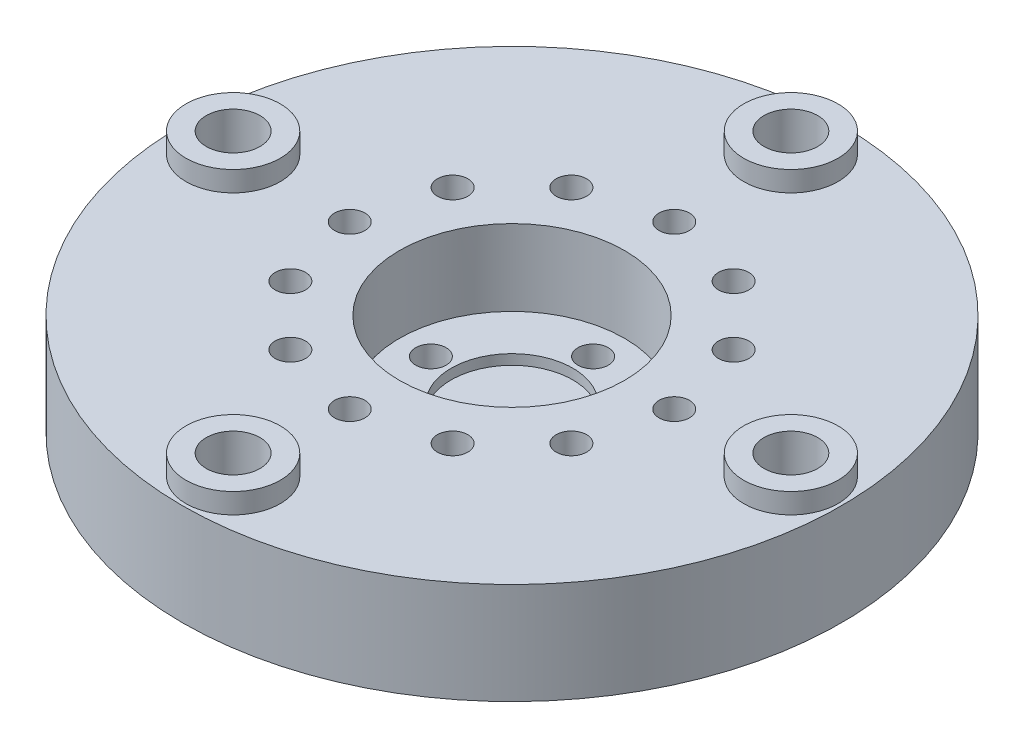
from build123d import *

# Parameters (mm, degrees)
SKETCH1_R           = 32.5
SKETCH1_R_2         = 2.65
SKETCH1_R_3         = 11.1
BOSS_EXTRUDE1_DEPTH = 3
SKETCH2_R           = 4.65
SKETCH2_R_2         = 2.65
BOSS_EXTRUDE2_DEPTH = 2
SKETCH3_R           = 32.5
SKETCH3_R_2         = 11.1
SKETCH3_R_3         = 4.25
BOSS_EXTRUDE3_DEPTH = 7
SKETCH4_R           = 11.1
SKETCH4_R_2         = 1.5
BOSS_EXTRUDE4_DEPTH = 2.5
SKETCH5_R           = 1.5
CUT_EXTRUDE1_DEPTH  = 13
SKETCH6_R           = 6
CUT_EXTRUDE2_DEPTH  = 1


with BuildPart() as part:
    # Sketch1 → Boss-Extrude1 (new body)
    with BuildSketch(Plane(origin=(0, 0, 0), x_dir=(1, 0, 0), z_dir=(0, 1, 0))):
        Circle(SKETCH1_R)
        with Locations((0, 27.5)):
            Circle(SKETCH1_R_2, mode=Mode.SUBTRACT)
        with Locations((27.5, 0)):
            Circle(SKETCH1_R_2, mode=Mode.SUBTRACT)
        with Locations((0, -27.5)):
            Circle(SKETCH1_R_2, mode=Mode.SUBTRACT)
        with Locations((-27.5, 0)):
            Circle(SKETCH1_R_2, mode=Mode.SUBTRACT)
        Circle(SKETCH1_R_3, mode=Mode.SUBTRACT)
    extrude(amount=BOSS_EXTRUDE1_DEPTH)

    # Sketch2 → Boss-Extrude2 (add)
    with BuildSketch(Plane(origin=(0, 3, 0), x_dir=(1, 0, 0), z_dir=(0, 1, 0))):
        with Locations((0, -27.5)):
            Circle(SKETCH2_R)
        with Locations((0, -27.5)):
            Circle(SKETCH2_R_2, mode=Mode.SUBTRACT)
        with Locations((27.5, 0)):
            Circle(SKETCH2_R)
        with Locations((27.5, 0)):
            Circle(SKETCH2_R_2, mode=Mode.SUBTRACT)
        with Locations((0, 27.5)):
            Circle(SKETCH2_R)
        with Locations((0, 27.5)):
            Circle(SKETCH2_R_2, mode=Mode.SUBTRACT)
        with Locations((-27.5, 0)):
            Circle(SKETCH2_R)
        with Locations((-27.5, 0)):
            Circle(SKETCH2_R_2, mode=Mode.SUBTRACT)
    extrude(amount=BOSS_EXTRUDE2_DEPTH)

    # Sketch3 → Boss-Extrude3 (add)
    with BuildSketch(Plane(origin=(0, 0, 0), x_dir=(-1, 0, 0), z_dir=(0, -1, 0))):
        Circle(SKETCH3_R)
        Circle(SKETCH3_R_2, mode=Mode.SUBTRACT)
        with Locations((0, 27.5)):
            Circle(SKETCH3_R_3, mode=Mode.SUBTRACT)
        with Locations((27.5, 0)):
            Circle(SKETCH3_R_3, mode=Mode.SUBTRACT)
        with Locations((0, -27.5)):
            Circle(SKETCH3_R_3, mode=Mode.SUBTRACT)
        with Locations((-27.5, 0)):
            Circle(SKETCH3_R_3, mode=Mode.SUBTRACT)
    extrude(amount=BOSS_EXTRUDE3_DEPTH)

    # Sketch4 → Boss-Extrude4 (add)
    with BuildSketch(Plane(origin=(0, -7, 0), x_dir=(-1, 0, 0), z_dir=(0, -1, 0))):
        Circle(SKETCH4_R)
        with Locations((0, 8)):
            Circle(SKETCH4_R_2, mode=Mode.SUBTRACT)
        with Locations((8, 0)):
            Circle(SKETCH4_R_2, mode=Mode.SUBTRACT)
        with Locations((0, -8)):
            Circle(SKETCH4_R_2, mode=Mode.SUBTRACT)
        with Locations((-8, 0)):
            Circle(SKETCH4_R_2, mode=Mode.SUBTRACT)
    extrude(amount=-BOSS_EXTRUDE4_DEPTH)

    # Sketch5 → Cut-Extrude1 (cut, through all)
    with BuildSketch(Plane.XZ.offset(7)):
        with Locations((0, 16)):
            Circle(SKETCH5_R)
        with Locations((8, 13.856406461)):
            Circle(SKETCH5_R)
        with Locations((13.856406461, 8)):
            Circle(SKETCH5_R)
        with Locations((16, 0)):
            Circle(SKETCH5_R)
        with Locations((13.856406461, -8)):
            Circle(SKETCH5_R)
        with Locations((8, -13.856406461)):
            Circle(SKETCH5_R)
        with Locations((0, -16)):
            Circle(SKETCH5_R)
        with Locations((-8, -13.856406461)):
            Circle(SKETCH5_R)
        with Locations((-13.856406461, -8)):
            Circle(SKETCH5_R)
        with Locations((-16, 0)):
            Circle(SKETCH5_R)
        with Locations((-13.856406461, 8)):
            Circle(SKETCH5_R)
        with Locations((-8, 13.856406461)):
            Circle(SKETCH5_R)
    extrude(amount=-CUT_EXTRUDE1_DEPTH, mode=Mode.SUBTRACT)

    # Sketch6 → Cut-Extrude2 (cut)
    with BuildSketch(Plane(origin=(0, -4.5, 0), x_dir=(1, 0, 0), z_dir=(0, 1, 0))):
        Circle(SKETCH6_R)
    extrude(amount=-CUT_EXTRUDE2_DEPTH, mode=Mode.SUBTRACT)


solid = part.part
